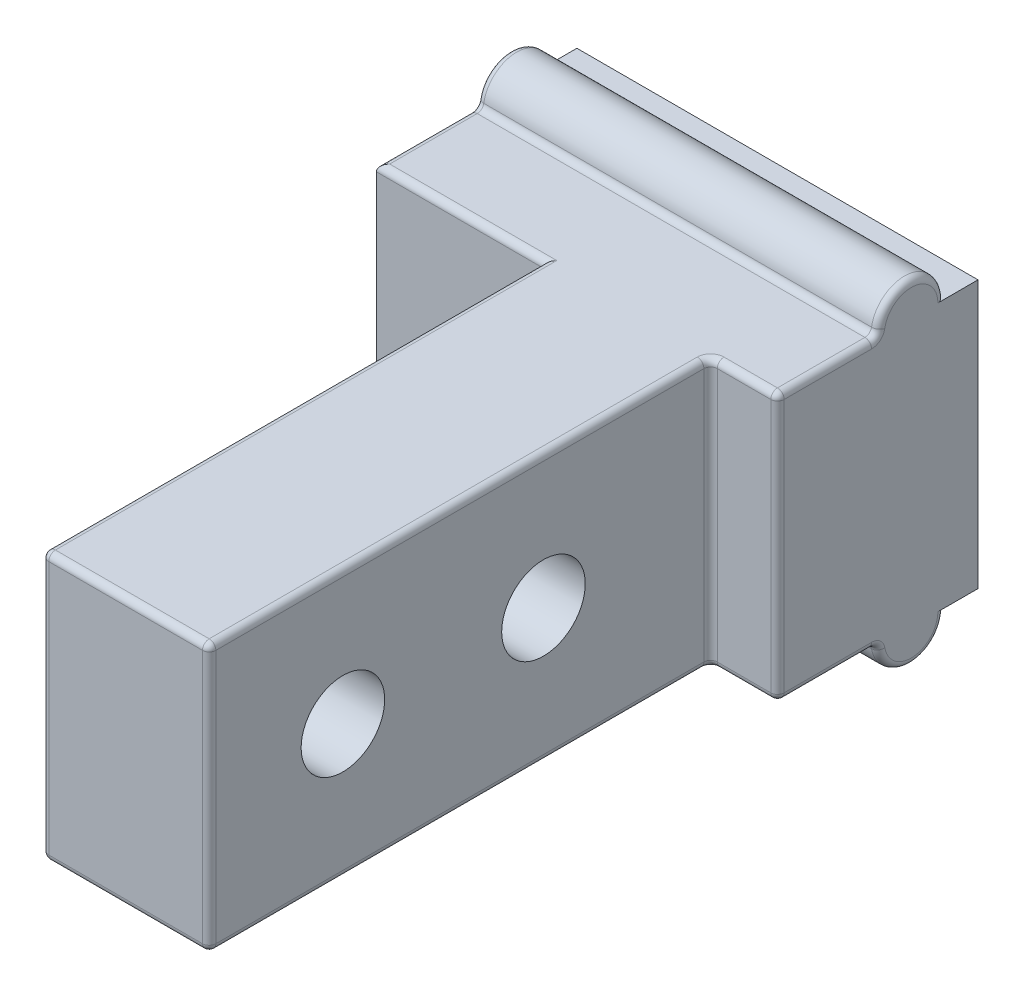
from build123d import *

# Parameters (mm, degrees)
SKETCH1_R               = 1
SKETCH1_W               = 4
SKETCH1_H               = 8
BOSS_EXTRUDE1_DEPTH     = 12
SKETCH2_W               = 12
SKETCH2_H               = 8
BOSS_EXTRUDE2_DEPTH     = 2
SKETCH3_W               = 5
SKETCH3_H               = 8
BOSS_EXTRUDE3_DEPTH     = 15
SKETCH4_R               = 1.25
CUT_EXTRUDE1_DEPTH      = 6
CUT_EXTRUDE1_DEPTH_BACK = 8
FILLET1_R               = 0.2


with BuildPart() as part:
    # Sketch1 → Boss-Extrude1 (new body)
    with BuildSketch(Plane(origin=(0, 0, 0), x_dir=(0, 0, -1), z_dir=(1, 0, 0))):
        with Locations((0, -4)):
            Circle(SKETCH1_R)
        with Locations((0, 4)):
            Circle(SKETCH1_R)
        Rectangle(SKETCH1_W, SKETCH1_H)
        with BuildLine():
            ThreePointArc((-1, -4), (0, -5), (1, -4))
            Line((1, -4), (-1, -4))
        make_face()
        with BuildLine():
            Line((-1, -4), (1, -4))
            ThreePointArc((1, -4), (0, -3), (-1, -4))
        make_face()
    extrude(amount=BOSS_EXTRUDE1_DEPTH)

    # Sketch2 → Boss-Extrude2 (add)
    with BuildSketch(Plane.XY.offset(2)):
        with Locations((6, 0)):
            Rectangle(SKETCH2_W, SKETCH2_H)
    extrude(amount=BOSS_EXTRUDE2_DEPTH)

    # Sketch3 → Boss-Extrude3 (add)
    with BuildSketch(Plane.XY.offset(4)):
        with Locations((7.5, 0)):
            Rectangle(SKETCH3_W, SKETCH3_H)
    extrude(amount=BOSS_EXTRUDE3_DEPTH)

    # Sketch4 → Cut-Extrude1 (cut, two sides)
    with BuildSketch(Plane.ZY.offset(-5)) as cut_extrude1_sk:
        with Locations((15, 0)):
            Circle(SKETCH4_R)
        with Locations((9, 0)):
            Circle(SKETCH4_R)
    extrude(amount=CUT_EXTRUDE1_DEPTH, mode=Mode.SUBTRACT)
    extrude(cut_extrude1_sk.sketch, amount=-CUT_EXTRUDE1_DEPTH_BACK, mode=Mode.SUBTRACT)

    # Fillet1
    fillet1_edges = [part.edges().sort_by_distance(p)[0] for p in [
        (12, -5, 0),
        (0, -5, 0),
        (12, 5, 0),
        (0, 5, 0),
        (2.5, -4, 4),
        (5, -4, 11.5),
        (10, -4, 11.5),
        (11, -4, 4),
        (12, -4, 2.5),
        (6, -4, 1),
        (0, -4, 2.5),
        (10, 0, 19),
        (7.5, -4, 19),
        (5, 0, 19),
        (6, 4, 1),
        (12, 4, 2.5),
        (11, 4, 4),
        (10, 4, 11.5),
        (7.5, 4, 19),
        (5, 4, 11.5),
        (2.5, 4, 4),
        (0, 4, 2.5),
        (12, 0, 4),
        (10, 0, 4),
    ]]
    fillet(fillet1_edges, radius=FILLET1_R)


solid = part.part
